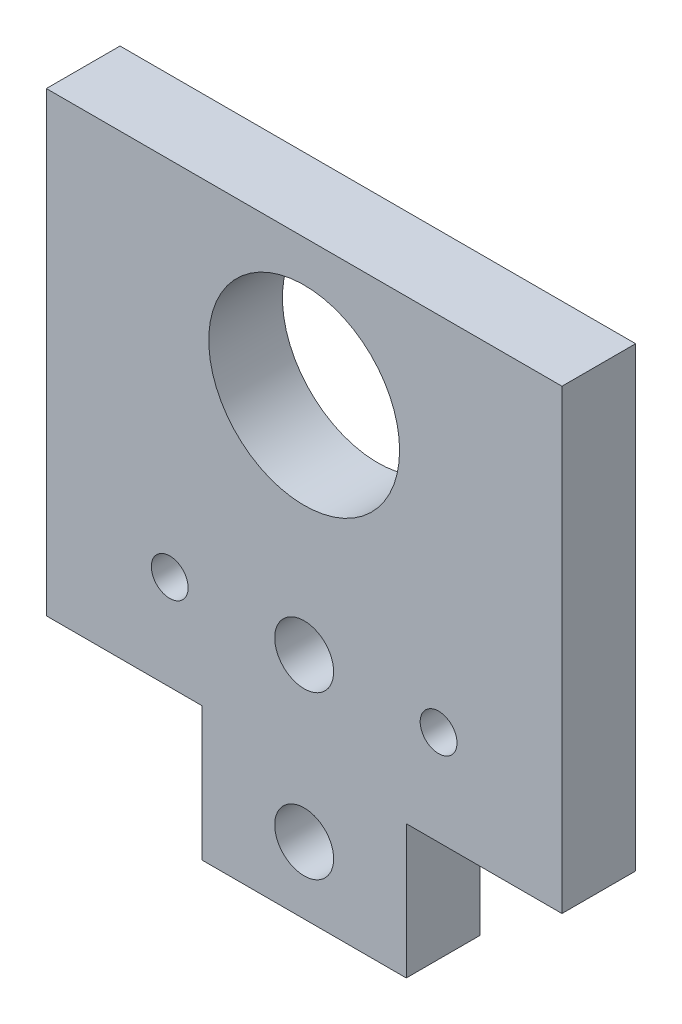
from build123d import *

# Parameters (mm, degrees)
BOSS_EXTRUDE1_DEPTH = 10
SKETCH2_R           = 4
SKETCH2_R_2         = 2.5
CUT_EXTRUDE1_DEPTH  = 11
SKETCH8_R           = 12.955
CUT_EXTRUDE9_DEPTH  = 10


with BuildPart() as part:
    # Sketch1 → Boss-Extrude1 (new body)
    with BuildSketch(Plane.XY):
        Polygon((-35, 40.07390675), (35, 40.07390675), (35, -21.92609325), (13.861088822, -21.92609325), (13.861088822, -40.07390675), (-13.861088822, -40.07390675), (-13.861088822, -21.92609325), (-35, -21.92609325), align=None)
    extrude(amount=BOSS_EXTRUDE1_DEPTH)

    # Sketch2 → Cut-Extrude1 (cut, through all)
    with BuildSketch(Plane.XY.offset(10)):
        with Locations((0, -31)):
            Circle(SKETCH2_R)
        with Locations((0, -9)):
            Circle(SKETCH2_R)
        with Locations((-18.25, -9)):
            Circle(SKETCH2_R_2)
        with Locations((18.25, -9)):
            Circle(SKETCH2_R_2)
    extrude(amount=-CUT_EXTRUDE1_DEPTH, mode=Mode.SUBTRACT)

    # Sketch8 → Cut-Extrude9 (cut)
    with BuildSketch(Plane.XY.offset(10)):
        with Locations((0, 21.51390675)):
            Circle(SKETCH8_R)
    extrude(amount=-CUT_EXTRUDE9_DEPTH, mode=Mode.SUBTRACT)


solid = part.part
